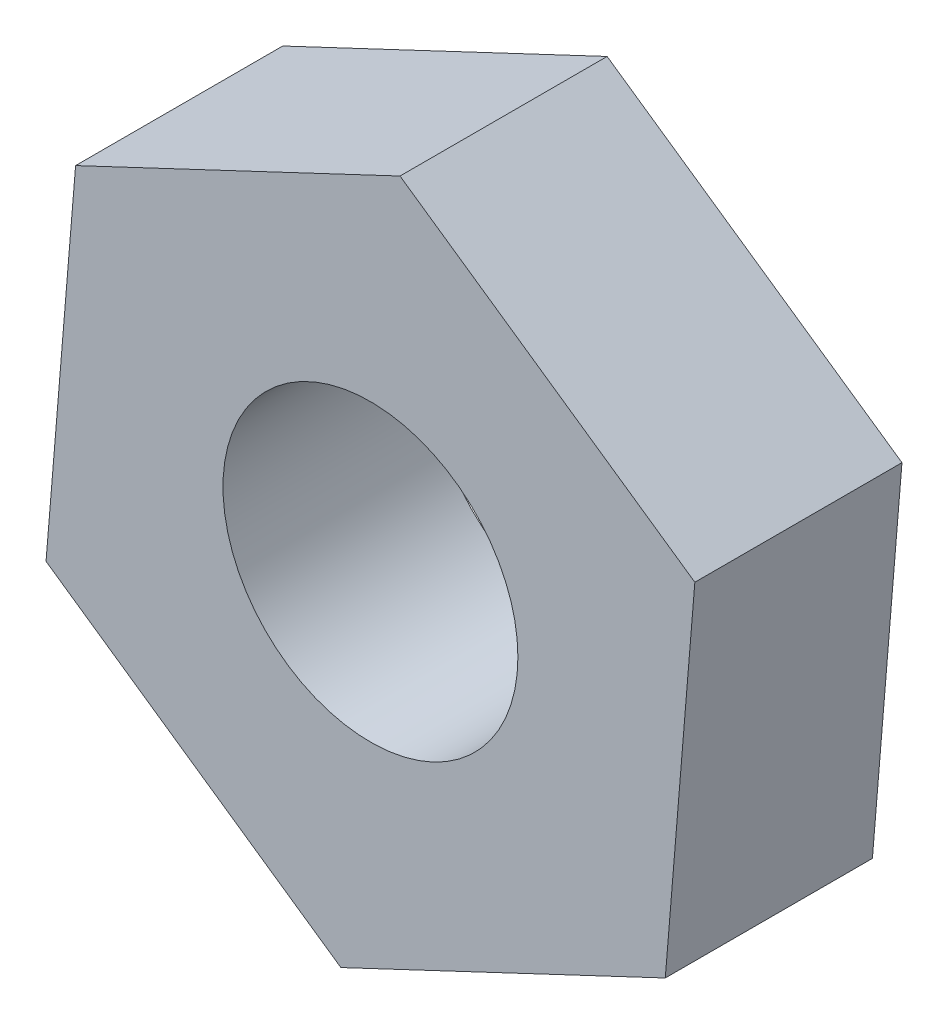
from build123d import *

# Parameters (mm, degrees)
BOSS_EXTRUDE1_DEPTH   = 1.5875
F_4_40_TAPPED_HOLE1_D = 2.2606


with BuildPart() as part:
    # Sketch1 → Boss-Extrude1 (new body)
    with BuildSketch(Plane.XY):
        Polygon((2.2598516, -1.566377826), (2.48644879, 1.173899982), (0.226597189, 2.740277808), (-2.2598516, 1.566377826), (-2.48644879, -1.173899982), (-0.226597189, -2.740277808), align=None)
    extrude(amount=BOSS_EXTRUDE1_DEPTH)

    # #4-40 Tapped Hole1 (through all)
    with Locations(Plane.XY.offset(1.5875)):
        with Locations((0, 0)):
            Hole(F_4_40_TAPPED_HOLE1_D / 2)


solid = part.part
